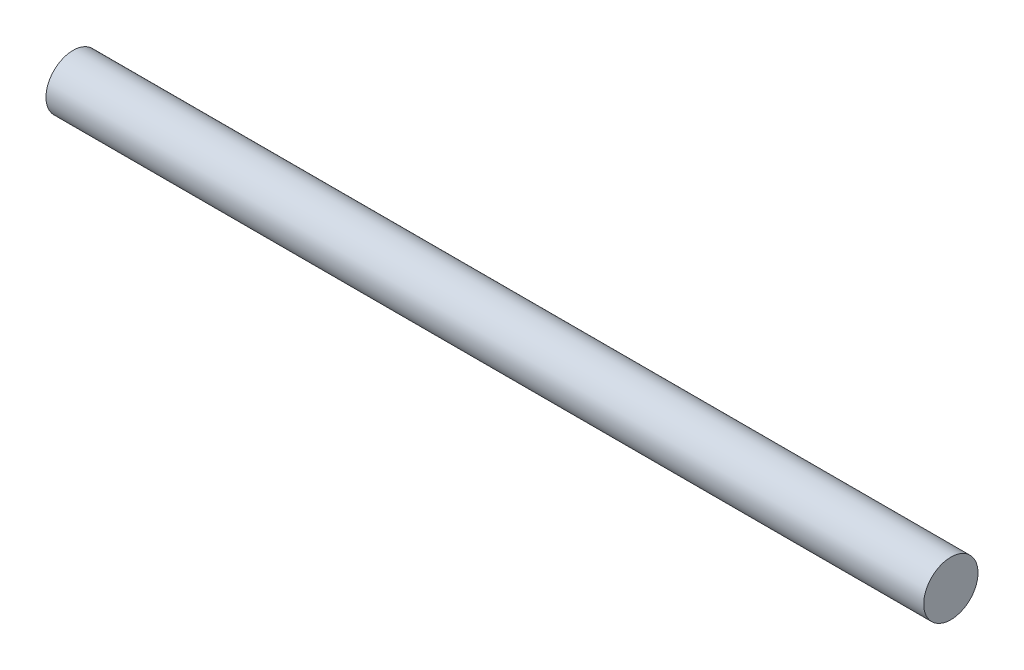
from build123d import *

# Parameters (mm, degrees)
SKETCH1_R           = 1.5
BOSS_EXTRUDE1_DEPTH = 24.25


with BuildPart() as part:
    # Sketch1 → Boss-Extrude1 (new body, symmetric)
    with BuildSketch(Plane(origin=(0, 0, 0), x_dir=(0, 0, -1), z_dir=(1, 0, 0))):
        Circle(SKETCH1_R)
    extrude(amount=BOSS_EXTRUDE1_DEPTH, both=True)


solid = part.part
